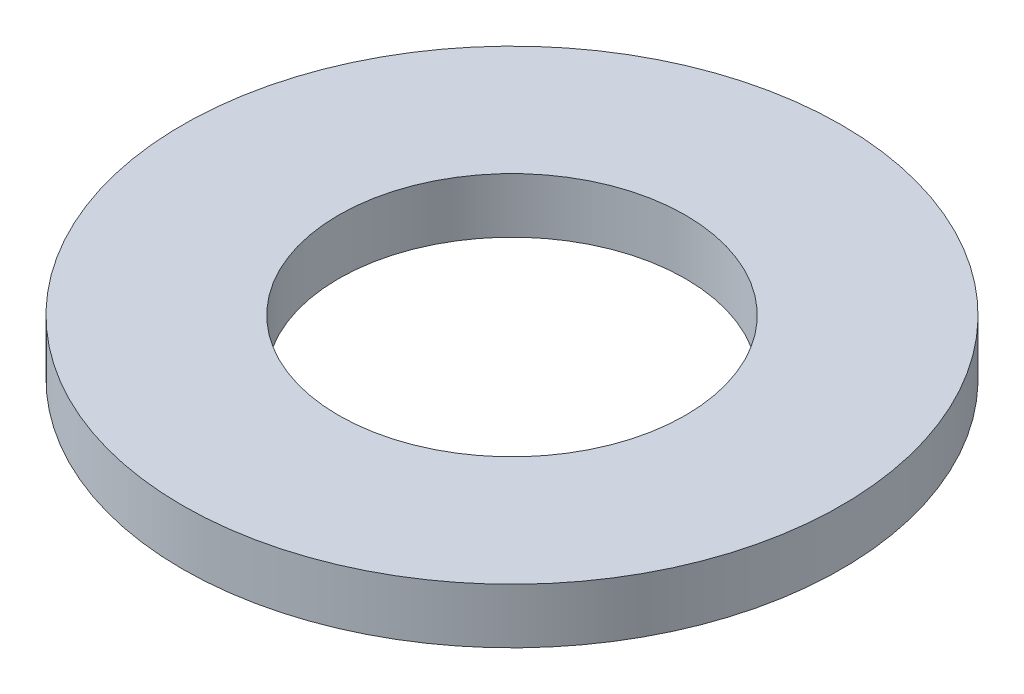
from build123d import *

# Parameters (mm, degrees)
SKETCH1_R           = 38
SKETCH1_R_2         = 20
BOSS_EXTRUDE1_DEPTH = 6.35


with BuildPart() as part:
    # Sketch1 → Boss-Extrude1 (new body)
    with BuildSketch(Plane(origin=(0, 0, 0), x_dir=(1, 0, 0), z_dir=(0, 1, 0))):
        Circle(SKETCH1_R)
        Circle(SKETCH1_R_2, mode=Mode.SUBTRACT)
    extrude(amount=BOSS_EXTRUDE1_DEPTH)


solid = part.part
